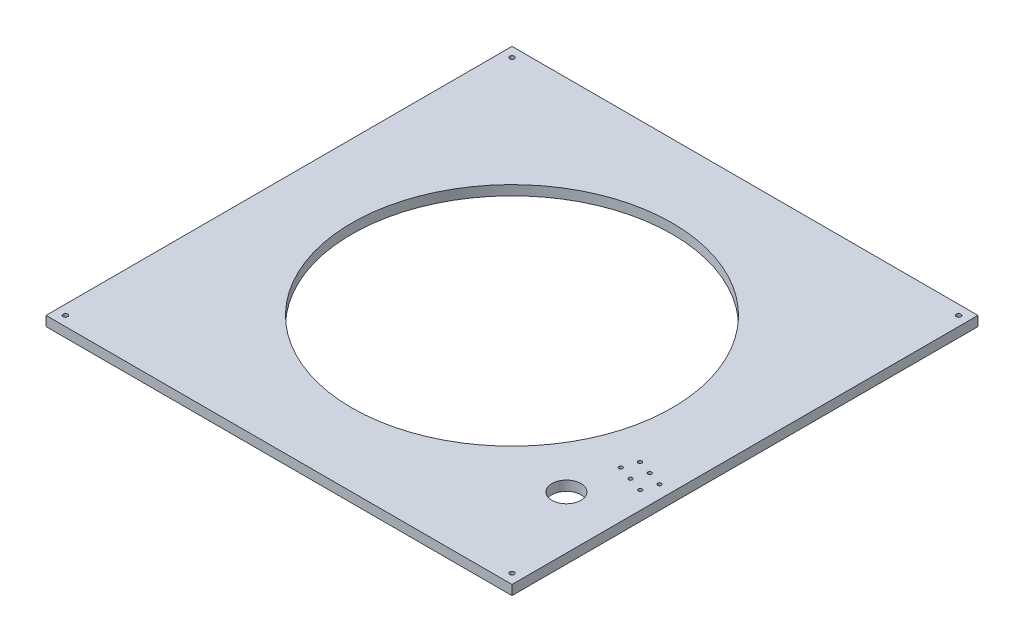
from build123d import *

# Parameters (mm, degrees)
SKETCH1_W           = 609.6
SKETCH1_H           = 609.6
BOSS_EXTRUDE1_DEPTH = 12.7
SKETCH2_R           = 209.55
CUT_EXTRUDE1_DEPTH  = 13.7
SKETCH3_R           = 19
CUT_EXTRUDE2_DEPTH  = 13.7
SKETCH4_R           = 2.5
CUT_EXTRUDE3_DEPTH  = 13.7
SKETCH5_R           = 3
CUT_EXTRUDE4_DEPTH  = 13.7


with BuildPart() as part:
    # Sketch1 → Boss-Extrude1 (new body)
    with BuildSketch(Plane(origin=(0, 0, 0), x_dir=(1, 0, 0), z_dir=(0, 1, 0))):
        with Locations((254.294265396, -260.340726581)):
            Rectangle(SKETCH1_W, SKETCH1_H)
    extrude(amount=BOSS_EXTRUDE1_DEPTH)

    # Sketch2 → Cut-Extrude1 (cut, through all)
    with BuildSketch(Plane(origin=(0, 12.7, 0), x_dir=(1, 0, 0), z_dir=(0, 1, 0))):
        with Locations((254.294265396, -260.340726581)):
            Circle(SKETCH2_R)
    extrude(amount=-CUT_EXTRUDE1_DEPTH, mode=Mode.SUBTRACT)

    # Sketch3 → Cut-Extrude2 (cut, through all)
    with BuildSketch(Plane.XZ):
        with Locations((489.894265396, 424.740726581)):
            Circle(SKETCH3_R)
    extrude(amount=-CUT_EXTRUDE2_DEPTH, mode=Mode.SUBTRACT)

    # Sketch4 → Cut-Extrude3 (cut, through all)
    with BuildSketch(Plane(origin=(0, 12.7, 0), x_dir=(1, 0, 0), z_dir=(0, 1, 0))):
        with Locations((542.094265396, -355.140726581)):
            Circle(SKETCH4_R)
        with Locations((523.094265396, -348.895728582)):
            Circle(SKETCH4_R)
        with Locations((504.094265396, -342.650730584)):
            Circle(SKETCH4_R)
        with Locations((497.849267397, -361.650730584)):
            Circle(SKETCH4_R)
        with Locations((516.849267397, -367.895728582)):
            Circle(SKETCH4_R)
        with Locations((535.849267397, -374.140726581)):
            Circle(SKETCH4_R)
    extrude(amount=-CUT_EXTRUDE3_DEPTH, mode=Mode.SUBTRACT)

    # Sketch5 → Cut-Extrude4 (cut, through all)
    with BuildSketch(Plane(origin=(0, 12.7, 0), x_dir=(1, 0, 0), z_dir=(0, 1, 0))):
        with Locations((546.394265396, -552.440726581)):
            Circle(SKETCH5_R)
        with Locations((-37.805734604, -552.440726581)):
            Circle(SKETCH5_R)
        with Locations((-37.805734604, 31.759273419)):
            Circle(SKETCH5_R)
        with Locations((546.394265396, 31.759273419)):
            Circle(SKETCH5_R)
    extrude(amount=-CUT_EXTRUDE4_DEPTH, mode=Mode.SUBTRACT)


solid = part.part
